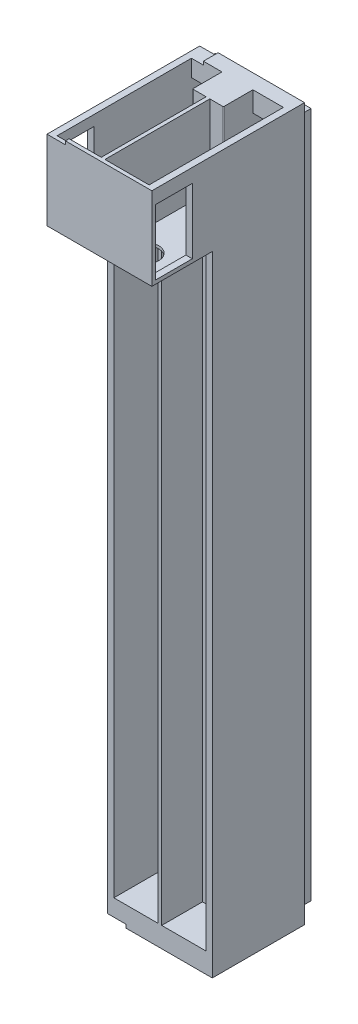
from build123d import *

# Parameters (mm, degrees)
SZKIC1_W                     = 53
SZKIC1_H                     = 374
SZKIC1_W_2                   = 24
SZKIC1_H_2                   = 365
DODANIE_WYCI_GNI_CIE2_DEPTH  = 12
SZKIC2_W                     = 12
SZKIC2_H                     = 3.5
WYTNIJ_WYCI_GNI_CIE1_DEPTH   = 2
SZKIC3_W                     = 53
SZKIC3_H                     = 374
DODANIE_WYCI_GNI_CIE3_DEPTH  = 2
SZKIC4_W                     = 13.3
SZKIC4_H                     = 30.500081729
SZKIC4_W_2                   = 9.4
SZKIC4_H_2                   = 64.96
WYTNIJ_WYCI_GNI_CIE2_DEPTH   = 2
SZKIC5_W                     = 2
SZKIC5_H                     = 374
DODANIE_WYCI_GNI_CIE4_DEPTH  = 43
DODANIE_WYCI_GNI_CIE5_DEPTH  = 41.5
SZKIC7_W                     = 25.5
SZKIC7_H                     = 38.500081729
DODANIE_WYCI_GNI_CIE6_DEPTH  = 1.5
DODANIE_WYCI_GNI_CIE7_DEPTH  = 43
DODANIE_WYCI_GNI_CIE8_DEPTH  = 43
SZKIC15_W                    = 57
SZKIC15_H                    = 374
DODANIE_WYCI_GNI_CIE10_DEPTH = 1
SZKIC16_W                    = 57
SZKIC16_H                    = 374
DODANIE_WYCI_GNI_CIE11_DEPTH = 1
SZKIC17_W                    = 55
SZKIC17_H                    = 57
SZKIC17_W_2                  = 24
SZKIC17_H_2                  = 41.5
DODANIE_WYCI_GNI_CIE12_DEPTH = 1
SZKIC18_W                    = 55
SZKIC18_H                    = 57
DODANIE_WYCI_GNI_CIE13_DEPTH = 1
SZKIC19_W                    = 55
SZKIC19_H                    = 376
SZKIC19_W_2                  = 52
SZKIC19_H_2                  = 373
WYTNIJ_WYCI_GNI_CIE7_DEPTH   = 6
SZKIC23_W                    = 24
SZKIC23_H                    = 38.000081729
WYTNIJ_WYCI_GNI_CIE11_DEPTH  = 10
DODANIE_WYCI_GNI_CIE14_DEPTH = 32
SZKIC25_W                    = 24
SZKIC25_H                    = 2
DODANIE_WYCI_GNI_CIE15_DEPTH = 38
SZKIC26_W                    = 24
SZKIC26_H                    = 2
DODANIE_WYCI_GNI_CIE16_DEPTH = 38
SZKIC27_R                    = 7
WYTNIJ_WYCI_GNI_CIE12_DEPTH  = 10
SZKIC28_W                    = 20
SZKIC28_H                    = 35.5
WYTNIJ_WYCI_GNI_CIE13_DEPTH  = 3
SZKIC29_W                    = 20
SZKIC29_H                    = 35.5
WYTNIJ_WYCI_GNI_CIE14_DEPTH  = 3
SZKIC33_W                    = 55
SZKIC33_H                    = 83
SZKIC33_W_2                  = 24
SZKIC33_H_2                  = 73
DODANIE_WYCI_GNI_CIE17_DEPTH = 5.5
SZKIC34_W                    = 55
SZKIC34_H                    = 51
DODANIE_WYCI_GNI_CIE18_DEPTH = 5.5
SZKIC35_W                    = 20
SZKIC35_H                    = 35.5
DODANIE_WYCI_GNI_CIE19_DEPTH = 1
SZKIC36_W                    = 20
SZKIC36_H                    = 35.5
DODANIE_WYCI_GNI_CIE20_DEPTH = 1
SZKIC37_W                    = 24
SZKIC37_H                    = 330.999918271
WYTNIJ_WYCI_GNI_CIE15_DEPTH  = 2
SZKIC38_W                    = 24
SZKIC38_H                    = 330.999918271
WYTNIJ_WYCI_GNI_CIE16_DEPTH  = 2
WYTNIJ_WYCI_GNI_CIE17_DEPTH  = 2
SZKIC40_W                    = 2
SZKIC40_H                    = 3.5
WYTNIJ_WYCI_GNI_CIE18_DEPTH  = 14
DODANIE_WYCI_GNI_CIE21_DEPTH = 331
SZKIC42_W                    = 10
SZKIC42_H                    = 324.999918271
WYTNIJ_WYCI_GNI_CIE19_DEPTH  = 2
DODANIE_WYCI_GNI_CIE22_DEPTH = 18
SZKIC44_W                    = 10
SZKIC44_H                    = 324.999918271
DODANIE_WYCI_GNI_CIE23_DEPTH = 10
SZKIC45_W                    = 2
SZKIC45_H                    = 43.500081729
DODANIE_WYCI_GNI_CIE24_DEPTH = 7.4
SZKIC46_W                    = 7.4
SZKIC46_H                    = 11
DODANIE_WYCI_GNI_CIE25_DEPTH = 14
SZKIC47_W                    = 2
SZKIC47_H                    = 32.500081729
DODANIE_WYCI_GNI_CIE26_DEPTH = 24
WYTNIJ_WYCI_GNI_CIE20_DEPTH  = 1.85
SZKIC49_W                    = 10
SZKIC49_H                    = 51
WYTNIJ_WYCI_GNI_CIE21_DEPTH  = 1.85
WYTNIJ_WYCI_GNI_CIE22_DEPTH  = 0.85
DODANIE_WYCI_GNI_CIE27_DEPTH = 7.4
SZKIC52_W                    = 7.4
SZKIC52_H                    = 11
DODANIE_WYCI_GNI_CIE28_DEPTH = 14
SZKIC53_W                    = 2
SZKIC53_H                    = 32.500081729
DODANIE_WYCI_GNI_CIE30_DEPTH = 24
SZKIC54_W                    = 24
SZKIC54_H                    = 1.5
DODANIE_WYCI_GNI_CIE31_DEPTH = 10
ZAOKR_GLENIE1_R              = 0.5
ZAOKR_GLENIE2_R              = 0.5


with BuildPart() as part:
    # Szkic1 → Dodanie-wyciągnięcie2 (new body)
    with BuildSketch(Plane.XY):
        with Locations((-65.426891924, -133.239080048)):
            Rectangle(SZKIC1_W, SZKIC1_H)
        with Locations((-78.426891924, -133.239080048)):
            Rectangle(SZKIC1_W_2, SZKIC1_H_2, mode=Mode.SUBTRACT)
        with Locations((-52.426891924, -133.239080048)):
            Rectangle(SZKIC1_W_2, SZKIC1_H_2, mode=Mode.SUBTRACT)
    extrude(amount=DODANIE_WYCI_GNI_CIE2_DEPTH)

    # Szkic2 → Wytnij-wyciągnięcie1 (cut)
    with BuildSketch(Plane.ZY.offset(66.426891924)):
        with Locations((6, 47.510919952)):
            Rectangle(SZKIC2_W, SZKIC2_H)
    extrude(amount=-WYTNIJ_WYCI_GNI_CIE1_DEPTH, mode=Mode.SUBTRACT)

    # Szkic3 → Dodanie-wyciągnięcie3 (add)
    with BuildSketch(Plane.XY.offset(12)):
        with Locations((-65.426891924, -133.239080048)):
            Rectangle(SZKIC3_W, SZKIC3_H)
    extrude(amount=DODANIE_WYCI_GNI_CIE3_DEPTH)

    # Szkic4 → Wytnij-wyciągnięcie2 (cut)
    with BuildSketch(Plane.XY.offset(14)):
        Polygon((-46.926891924, -11.039080048), (-56.326891924, -11.039080048), (-56.326891924, -35.399080048), (-56.326891924, -40.479080048), (-46.926891924, -40.479080048), (-46.926891924, -35.399080048), align=None)
        with Locations((-47.076891924, 34.010879088)):
            Rectangle(SZKIC4_W, SZKIC4_H)
        with Locations((-83.776891924, 34.010879088)):
            Rectangle(SZKIC4_W, SZKIC4_H)
        Polygon((-74.526891924, -35.399080048), (-74.526891924, -40.479080048), (-83.926891924, -40.479080048), (-83.926891924, -35.399080048), (-83.926891924, -11.039080048), (-74.526891924, -11.039080048), align=None)
        with Locations((-51.626891924, -133.719080048)):
            Rectangle(SZKIC4_W_2, SZKIC4_H_2)
        with Locations((-79.226891924, -133.719080048)):
            Rectangle(SZKIC4_W_2, SZKIC4_H_2)
    extrude(amount=-WYTNIJ_WYCI_GNI_CIE2_DEPTH, mode=Mode.SUBTRACT)

    # Szkic5 → Dodanie-wyciągnięcie4 (add)
    with BuildSketch(Plane.XY.offset(14)):
        with Locations((-65.426891924, -133.239080048)):
            Rectangle(SZKIC5_W, SZKIC5_H)
    extrude(amount=DODANIE_WYCI_GNI_CIE4_DEPTH)

    # Szkic6 → Dodanie-wyciągnięcie5 (add)
    with BuildSketch(Plane.XY.offset(14)):
        Polygon((-64.426891924, 16.760838223), (-40.426891924, 16.760838223), (-40.426891924, 53.760919952), (-38.926891924, 53.760919952), (-38.926891924, 15.260838223), (-64.426891924, 15.260838223), align=None)
        Polygon((-90.426891924, 53.760919952), (-91.926891924, 53.760919952), (-91.926891924, 15.260838223), (-66.426891924, 15.260838223), (-66.426891924, 16.760838223), (-90.426891924, 16.760838223), align=None)
    extrude(amount=DODANIE_WYCI_GNI_CIE5_DEPTH)

    # Szkic7 → Dodanie-wyciągnięcie6 (add)
    with BuildSketch(Plane.XY.offset(55.5)):
        with Locations((-51.676891924, 34.510879088)):
            Rectangle(SZKIC7_W, SZKIC7_H)
        with Locations((-79.176891924, 34.510879088)):
            Rectangle(SZKIC7_W, SZKIC7_H)
    extrude(amount=DODANIE_WYCI_GNI_CIE6_DEPTH)

    # Szkic10 → Dodanie-wyciągnięcie7 (add)
    with BuildSketch(Plane.XY.offset(14)):
        Polygon((-91.926891924, 15.260838223), (-91.926891924, -320.239080048), (-66.426891924, -320.239080048), (-66.426891924, -315.739080048), (-90.426891924, -315.739080048), (-90.426891924, 15.260838223), align=None)
    extrude(amount=DODANIE_WYCI_GNI_CIE7_DEPTH)

    # Szkic11 → Dodanie-wyciągnięcie8 (add)
    with BuildSketch(Plane.XY.offset(14)):
        Polygon((-38.926891924, 15.260838223), (-38.926891924, -320.239080048), (-64.426891924, -320.239080048), (-64.426891924, -315.739080048), (-40.426891924, -315.739080048), (-40.426891924, 15.260838223), align=None)
    extrude(amount=DODANIE_WYCI_GNI_CIE8_DEPTH)

    # Szkic15 → Dodanie-wyciągnięcie10 (add)
    with BuildSketch(Plane.ZY.offset(91.926891924)):
        with Locations((28.5, -133.239080048)):
            Rectangle(SZKIC15_W, SZKIC15_H)
    extrude(amount=DODANIE_WYCI_GNI_CIE10_DEPTH)

    # Szkic16 → Dodanie-wyciągnięcie11 (add)
    with BuildSketch(Plane(origin=(-38.926891924, 0, 0), x_dir=(0, 0, -1), z_dir=(1, 0, 0))):
        with Locations((-28.5, -133.239080048)):
            Rectangle(SZKIC16_W, SZKIC16_H)
    extrude(amount=DODANIE_WYCI_GNI_CIE11_DEPTH)

    # Szkic17 → Dodanie-wyciągnięcie12 (add)
    with BuildSketch(Plane(origin=(0, 53.760919952, 0), x_dir=(1, 0, 0), z_dir=(0, 1, 0))):
        with Locations((-65.426891924, -28.5)):
            Rectangle(SZKIC17_W, SZKIC17_H)
        with Locations((-52.426891924, -34.75)):
            Rectangle(SZKIC17_W_2, SZKIC17_H_2, mode=Mode.SUBTRACT)
        with Locations((-78.426891924, -34.75)):
            Rectangle(SZKIC17_W_2, SZKIC17_H_2, mode=Mode.SUBTRACT)
    extrude(amount=DODANIE_WYCI_GNI_CIE12_DEPTH)

    # Szkic18 → Dodanie-wyciągnięcie13 (add)
    with BuildSketch(Plane.XZ.offset(320.239080048)):
        with Locations((-65.426891924, 28.5)):
            Rectangle(SZKIC18_W, SZKIC18_H)
    extrude(amount=DODANIE_WYCI_GNI_CIE13_DEPTH)

    # Szkic19 → Wytnij-wyciągnięcie7 (cut)
    with BuildSketch(Plane(origin=(0, 0, 0), x_dir=(-1, 0, 0), z_dir=(0, 0, -1))):
        with Locations((65.426891924, -133.239080048)):
            Rectangle(SZKIC19_W, SZKIC19_H)
        with Locations((65.426891924, -133.239080048)):
            Rectangle(SZKIC19_W_2, SZKIC19_H_2, mode=Mode.SUBTRACT)
    extrude(amount=-WYTNIJ_WYCI_GNI_CIE7_DEPTH, mode=Mode.SUBTRACT)

    # Szkic23 → Wytnij-wyciągnięcie11 (cut)
    with BuildSketch(Plane.XY.offset(57)):
        with Locations((-52.426891924, 35.760879088)):
            Rectangle(SZKIC23_W, SZKIC23_H)
        with Locations((-78.426891924, 35.760879088)):
            Rectangle(SZKIC23_W, SZKIC23_H)
    extrude(amount=-WYTNIJ_WYCI_GNI_CIE11_DEPTH, mode=Mode.SUBTRACT)

    # Szkic24 → Dodanie-wyciągnięcie14 (add)
    with BuildSketch(Plane.XY.offset(57)):
        Polygon((-40.426891924, 54.760919952), (-37.926891924, 54.760919952), (-37.926891924, 15.260838223), (-92.926891924, 15.260838223), (-92.926891924, 54.760919952), (-90.426891924, 54.760919952), (-90.426891924, 16.760838223), (-66.426891924, 16.760838223), (-66.426891924, 54.760919952), (-64.426891924, 54.760919952), (-64.426891924, 16.760838223), (-40.426891924, 16.760838223), align=None)
    extrude(amount=DODANIE_WYCI_GNI_CIE14_DEPTH)

    # Szkic25 → Dodanie-wyciągnięcie15 (add)
    with BuildSketch(Plane(origin=(0, 16.760838223, 0), x_dir=(1, 0, 0), z_dir=(0, 1, 0))):
        with Locations((-52.426891924, -88)):
            Rectangle(SZKIC25_W, SZKIC25_H)
    extrude(amount=DODANIE_WYCI_GNI_CIE15_DEPTH)

    # Szkic26 → Dodanie-wyciągnięcie16 (add)
    with BuildSketch(Plane(origin=(0, 16.760838223, 0), x_dir=(1, 0, 0), z_dir=(0, 1, 0))):
        with Locations((-78.426891924, -88)):
            Rectangle(SZKIC26_W, SZKIC26_H)
    extrude(amount=DODANIE_WYCI_GNI_CIE16_DEPTH)

    # Szkic27 → Wytnij-wyciągnięcie12 (cut)
    with BuildSketch(Plane.XZ.offset(-15.260838223)):
        with Locations((-78.176891924, 76.5)):
            Circle(SZKIC27_R)
        with Locations((-52.676891924, 76.5)):
            Circle(SZKIC27_R)
    extrude(amount=-WYTNIJ_WYCI_GNI_CIE12_DEPTH, mode=Mode.SUBTRACT)

    # Szkic28 → Wytnij-wyciągnięcie13 (cut)
    with BuildSketch(Plane(origin=(-37.926891924, 0, 0), x_dir=(0, 0, -1), z_dir=(1, 0, 0))):
        with Locations((-77, 35.010838223)):
            Rectangle(SZKIC28_W, SZKIC28_H)
    extrude(amount=-WYTNIJ_WYCI_GNI_CIE13_DEPTH, mode=Mode.SUBTRACT)

    # Szkic29 → Wytnij-wyciągnięcie14 (cut)
    with BuildSketch(Plane.ZY.offset(92.926891924)):
        with Locations((77, 35.010838223)):
            Rectangle(SZKIC29_W, SZKIC29_H)
    extrude(amount=-WYTNIJ_WYCI_GNI_CIE14_DEPTH, mode=Mode.SUBTRACT)

    # Szkic33 → Dodanie-wyciągnięcie17 (add)
    with BuildSketch(Plane(origin=(0, 54.760919952, 0), x_dir=(1, 0, 0), z_dir=(0, 1, 0))):
        with Locations((-65.426891924, -47.5)):
            Rectangle(SZKIC33_W, SZKIC33_H)
        with Locations((-52.426891924, -50.5)):
            Rectangle(SZKIC33_W_2, SZKIC33_H_2, mode=Mode.SUBTRACT)
        with Locations((-78.426891924, -50.5)):
            Rectangle(SZKIC33_W_2, SZKIC33_H_2, mode=Mode.SUBTRACT)
    extrude(amount=DODANIE_WYCI_GNI_CIE17_DEPTH)

    # Szkic34 → Dodanie-wyciągnięcie18 (add)
    with BuildSketch(Plane.XZ.offset(321.239080048)):
        with Locations((-65.426891924, 31.5)):
            Rectangle(SZKIC34_W, SZKIC34_H)
    extrude(amount=DODANIE_WYCI_GNI_CIE18_DEPTH)

    # Szkic35 → Dodanie-wyciągnięcie19 (add)
    with BuildSketch(Plane.ZY.offset(92.926891924)):
        Polygon((89, 60.260919952), (89, 15.260838223), (57, 15.260838223), (57, -326.739080048), (6, -326.739080048), (6, 60.260919952), align=None)
        with Locations((77, 35.010838223)):
            Rectangle(SZKIC35_W, SZKIC35_H, mode=Mode.SUBTRACT)
    extrude(amount=DODANIE_WYCI_GNI_CIE19_DEPTH)

    # Szkic36 → Dodanie-wyciągnięcie20 (add)
    with BuildSketch(Plane(origin=(-37.926891924, 0, 0), x_dir=(0, 0, -1), z_dir=(1, 0, 0))):
        Polygon((-57, -326.739080048), (-57, 15.260838223), (-89, 15.260838223), (-89, 60.260919952), (-6, 60.260919952), (-6, -326.739080048), align=None)
        with Locations((-77, 35.010838223)):
            Rectangle(SZKIC36_W, SZKIC36_H, mode=Mode.SUBTRACT)
    extrude(amount=DODANIE_WYCI_GNI_CIE20_DEPTH)

    # Szkic37 → Wytnij-wyciągnięcie15 (cut)
    with BuildSketch(Plane.XY.offset(14)):
        with Locations((-52.426891924, -150.239120912)):
            Rectangle(SZKIC37_W, SZKIC37_H)
    extrude(amount=-WYTNIJ_WYCI_GNI_CIE15_DEPTH, mode=Mode.SUBTRACT)

    # Szkic38 → Wytnij-wyciągnięcie16 (cut)
    with BuildSketch(Plane.XY.offset(14)):
        with Locations((-78.426891924, -150.239120912)):
            Rectangle(SZKIC38_W, SZKIC38_H)
    extrude(amount=-WYTNIJ_WYCI_GNI_CIE16_DEPTH, mode=Mode.SUBTRACT)

    # Szkic39 → Wytnij-wyciągnięcie17 (cut)
    with BuildSketch(Plane(origin=(0, 0, 12), x_dir=(-1, 0, 0), z_dir=(0, 0, -1))):
        Polygon((90.426891924, 15.260838223), (66.426891924, 15.260838223), (66.426891924, 45.760919952), (64.426891924, 45.760919952), (64.426891924, 15.260838223), (40.426891924, 15.260838223), (40.426891924, 49.260919952), (90.426891924, 49.260919952), align=None)
    extrude(amount=-WYTNIJ_WYCI_GNI_CIE17_DEPTH, mode=Mode.SUBTRACT)

    # Szkic40 → Wytnij-wyciągnięcie18 (cut)
    with BuildSketch(Plane(origin=(0, 0, 14), x_dir=(-1, 0, 0), z_dir=(0, 0, -1))):
        with Locations((65.426891924, 47.510919952)):
            Rectangle(SZKIC40_W, SZKIC40_H)
    extrude(amount=-WYTNIJ_WYCI_GNI_CIE18_DEPTH, mode=Mode.SUBTRACT)

    # Szkic41 → Dodanie-wyciągnięcie21 (add)
    with BuildSketch(Plane(origin=(0, -315.739080048, 0), x_dir=(1, 0, 0), z_dir=(0, 1, 0))):
        Polygon((-52.426891924, -32), (-40.426891924, -32), (-40.426891924, -34), (-64.426891924, -34), (-64.426891924, -32), align=None)
    extrude(amount=DODANIE_WYCI_GNI_CIE21_DEPTH)

    # Szkic42 → Wytnij-wyciągnięcie19 (cut)
    with BuildSketch(Plane.XY.offset(34)):
        with Locations((-50.626891924, -147.239120912)):
            Rectangle(SZKIC42_W, SZKIC42_H)
    extrude(amount=-WYTNIJ_WYCI_GNI_CIE19_DEPTH, mode=Mode.SUBTRACT)

    # Szkic43 → Dodanie-wyciągnięcie22 (add)
    with BuildSketch(Plane(origin=(0, 0, 32), x_dir=(-1, 0, 0), z_dir=(0, 0, -1))):
        Polygon((45.626891924, 15.260838223), (45.626891924, -309.739080048), (55.626891924, -309.739080048), (55.626891924, 15.260838223), (57.626891924, 15.260838223), (57.626891924, -311.739161777), (43.626891924, -311.739161777), (43.626891924, 15.260838223), align=None)
    extrude(amount=DODANIE_WYCI_GNI_CIE22_DEPTH)

    # Szkic44 → Dodanie-wyciągnięcie23 (add)
    with BuildSketch(Plane(origin=(0, 0, 14), x_dir=(-1, 0, 0), z_dir=(0, 0, -1))):
        Polygon((64.426891924, 16.760838223), (40.426891924, 16.760838223), (40.426891924, 15.260838223), (43.626891924, 15.260838223), (43.626891924, -311.739161777), (57.626891924, -311.739161777), (57.626891924, 15.260838223), (64.426891924, 15.260838223), align=None)
        with Locations((50.626891924, -147.239120912)):
            Rectangle(SZKIC44_W, SZKIC44_H, mode=Mode.SUBTRACT)
    extrude(amount=DODANIE_WYCI_GNI_CIE23_DEPTH)

    # Szkic45 → Dodanie-wyciągnięcie24 (add)
    with BuildSketch(Plane(origin=(-64.426891924, 0, 0), x_dir=(0, 0, -1), z_dir=(1, 0, 0))):
        with Locations((-29, 38.510879088)):
            Rectangle(SZKIC45_W, SZKIC45_H)
    extrude(amount=DODANIE_WYCI_GNI_CIE24_DEPTH)

    # Szkic46 → Dodanie-wyciągnięcie25 (add)
    with BuildSketch(Plane.XY.offset(14)):
        with Locations((-60.726891924, 54.760919952)):
            Rectangle(SZKIC46_W, SZKIC46_H)
    extrude(amount=DODANIE_WYCI_GNI_CIE25_DEPTH)

    # Szkic47 → Dodanie-wyciągnięcie26 (add)
    with BuildSketch(Plane(origin=(0, 0, 28), x_dir=(-1, 0, 0), z_dir=(0, 0, -1))):
        with Locations((58.026891924, 33.010879088)):
            Rectangle(SZKIC47_W, SZKIC47_H)
    extrude(amount=DODANIE_WYCI_GNI_CIE26_DEPTH)

    # Szkic48 → Wytnij-wyciągnięcie20 (cut)
    with BuildSketch(Plane(origin=(0, 60.260919952, 0), x_dir=(1, 0, 0), z_dir=(0, 1, 0))):
        Polygon((-93.926891924, -6), (-83.926891924, -6), (-83.926891924, -14), (-90.426891924, -14), (-90.426891924, -87), (-83.926891924, -87), (-83.926891924, -89), (-93.926891924, -89), align=None)
    extrude(amount=-WYTNIJ_WYCI_GNI_CIE20_DEPTH, mode=Mode.SUBTRACT)

    # Szkic49 → Wytnij-wyciągnięcie21 (cut)
    with BuildSketch(Plane.XZ.offset(326.739080048)):
        with Locations((-88.926891924, 31.5)):
            Rectangle(SZKIC49_W, SZKIC49_H)
    extrude(amount=-WYTNIJ_WYCI_GNI_CIE21_DEPTH, mode=Mode.SUBTRACT)

    # Szkic50 → Wytnij-wyciągnięcie22 (cut)
    with BuildSketch(Plane.XY.offset(57)):
        Polygon((-40.426891924, 15.260838223), (-36.926891924, 15.260838223), (-36.926891924, -326.739080048), (-83.926891924, -326.739080048), (-83.926891924, -324.889080048), (-93.926891924, -324.889080048), (-93.926891924, 15.260838223), (-90.426891924, 15.260838223), (-90.426891924, -315.739080048), (-66.426891924, -315.739080048), (-66.426891924, 15.260838223), (-64.426891924, 15.260838223), (-64.426891924, -315.739080048), (-40.426891924, -315.739080048), align=None)
    extrude(amount=-WYTNIJ_WYCI_GNI_CIE22_DEPTH, mode=Mode.SUBTRACT)

    # Szkic51 → Dodanie-wyciągnięcie27 (add)
    with BuildSketch(Plane.ZY.offset(66.426891924)):
        Polygon((28, 45.760919952), (28, 16.760838223), (30, 16.760838223), (30, 60.260919952), (28, 60.260919952), align=None)
    extrude(amount=DODANIE_WYCI_GNI_CIE27_DEPTH)

    # Szkic52 → Dodanie-wyciągnięcie28 (add)
    with BuildSketch(Plane.XY.offset(14)):
        with Locations((-70.126891924, 54.760919952)):
            Rectangle(SZKIC52_W, SZKIC52_H)
    extrude(amount=DODANIE_WYCI_GNI_CIE28_DEPTH)

    # Szkic53 → Dodanie-wyciągnięcie30 (add)
    with BuildSketch(Plane(origin=(0, 0, 28), x_dir=(-1, 0, 0), z_dir=(0, 0, -1))):
        with Locations((72.826891924, 33.010879088)):
            Rectangle(SZKIC53_W, SZKIC53_H)
    extrude(amount=DODANIE_WYCI_GNI_CIE30_DEPTH)

    # Szkic54 → Dodanie-wyciągnięcie31 (add)
    with BuildSketch(Plane(origin=(0, 0, 14), x_dir=(-1, 0, 0), z_dir=(0, 0, -1))):
        with Locations((78.426891924, 16.010838223)):
            Rectangle(SZKIC54_W, SZKIC54_H)
    extrude(amount=DODANIE_WYCI_GNI_CIE31_DEPTH)

    # Zaokrąglenie1
    zaokr_glenie1_edges = [part.edges().sort_by_distance(p)[0] for p in [
        (-73.826891924, 38.510879088, 30),
    ]]
    fillet(zaokr_glenie1_edges, radius=ZAOKR_GLENIE1_R)

    # Zaokrąglenie2
    zaokr_glenie2_edges = [part.edges().sort_by_distance(p)[0] for p in [
        (-57.026891924, 38.510879088, 30),
    ]]
    fillet(zaokr_glenie2_edges, radius=ZAOKR_GLENIE2_R)


solid = part.part
